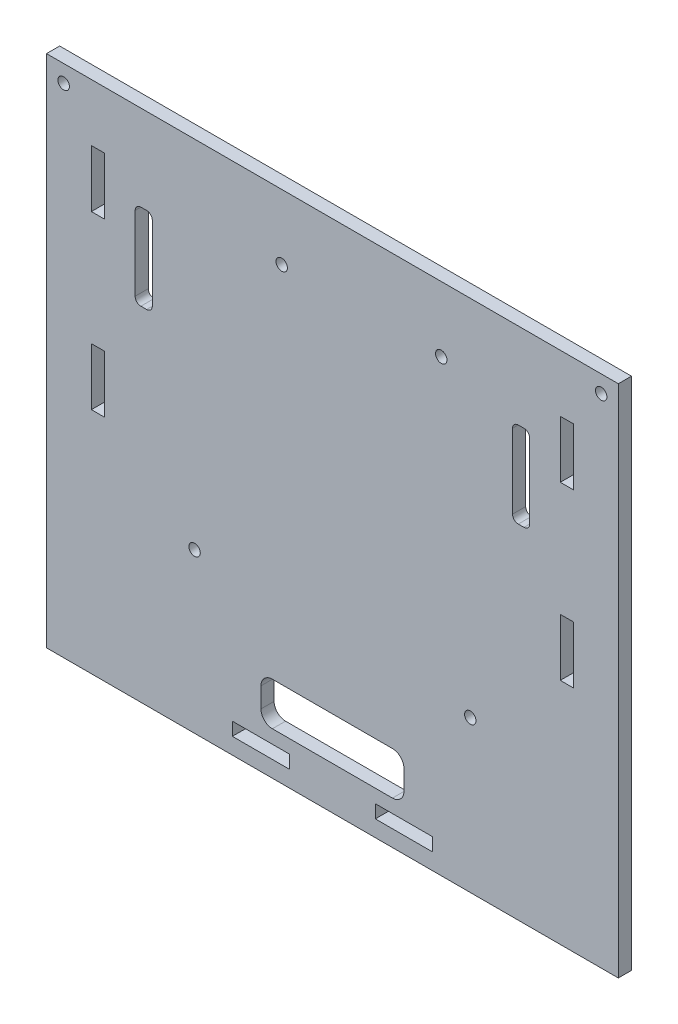
from build123d import *

# Parameters (mm, degrees)
BOSS_EXTRUDE1_DEPTH = 2.3
SKETCH7_W           = 2.3
SKETCH7_H           = 10
SKETCH7_W_2         = 10
SKETCH7_H_2         = 2.3
CUT_EXTRUDE2_DEPTH  = 3.3
SKETCH9_R           = 1
CUT_EXTRUDE4_DEPTH  = 3.3
SKETCH10_W          = 3
SKETCH10_H          = 15
SKETCH10_W_2        = 25
SKETCH10_H_2        = 7.5
CUT_EXTRUDE5_DEPTH  = 3.3
FILLET2_R           = 1
FILLET3_R           = 2


with BuildPart() as part:
    # Sketch1 → Boss-Extrude1 (new body)
    with BuildSketch(Plane.XY):
        Polygon((0, -57), (0, -90), (23, -90), (77, -90), (100, -90), (100, -57), (100, 0), (0, 0), align=None)
    extrude(amount=BOSS_EXTRUDE1_DEPTH)

    # Sketch7 → Cut-Extrude2 (cut, through all)
    with BuildSketch(Plane.XY.offset(2.3)):
        with Locations((91, -15)):
            Rectangle(SKETCH7_W, SKETCH7_H)
        with Locations((91, -45)):
            Rectangle(SKETCH7_W, SKETCH7_H)
        with Locations((9, -15)):
            Rectangle(SKETCH7_W, SKETCH7_H)
        with Locations((9, -45)):
            Rectangle(SKETCH7_W, SKETCH7_H)
        with Locations((37.5, -86)):
            Rectangle(SKETCH7_W_2, SKETCH7_H_2)
        with Locations((62.5, -86)):
            Rectangle(SKETCH7_W_2, SKETCH7_H_2)
    extrude(amount=-CUT_EXTRUDE2_DEPTH, mode=Mode.SUBTRACT)

    # Sketch9 → Cut-Extrude4 (cut, through all)
    with BuildSketch(Plane.XY.offset(2.3)):
        with Locations((3, -3)):
            Circle(SKETCH9_R)
        with Locations((97, -3)):
            Circle(SKETCH9_R)
        with Locations((41.13, -11.4)):
            Circle(SKETCH9_R)
        with Locations((69.03, -11.4)):
            Circle(SKETCH9_R)
        with Locations((25.89, -62.2)):
            Circle(SKETCH9_R)
        with Locations((74.11, -63.5)):
            Circle(SKETCH9_R)
    extrude(amount=-CUT_EXTRUDE4_DEPTH, mode=Mode.SUBTRACT)

    # Sketch10 → Cut-Extrude5 (cut, through all)
    with BuildSketch(Plane.XY.offset(2.3)):
        with Locations((17, -22.5)):
            Rectangle(SKETCH10_W, SKETCH10_H)
        with Locations((83, -22.5)):
            Rectangle(SKETCH10_W, SKETCH10_H)
        with Locations((50, -78.75)):
            Rectangle(SKETCH10_W_2, SKETCH10_H_2)
    extrude(amount=-CUT_EXTRUDE5_DEPTH, mode=Mode.SUBTRACT)

    # Fillet2
    fillet2_edges = [part.edges().sort_by_distance(p)[0] for p in [
        (15.5, -30, 1.15),
        (15.5, -15, 1.15),
        (18.5, -15, 1.15),
        (18.5, -30, 1.15),
        (81.5, -30, 1.15),
        (81.5, -15, 1.15),
        (84.5, -15, 1.15),
        (84.5, -30, 1.15),
    ]]
    fillet(fillet2_edges, radius=FILLET2_R)

    # Fillet3
    fillet3_edges = [part.edges().sort_by_distance(p)[0] for p in [
        (37.5, -82.5, 1.15),
        (37.5, -75, 1.15),
        (62.5, -75, 1.15),
        (62.5, -82.5, 1.15),
    ]]
    fillet(fillet3_edges, radius=FILLET3_R)


solid = part.part
